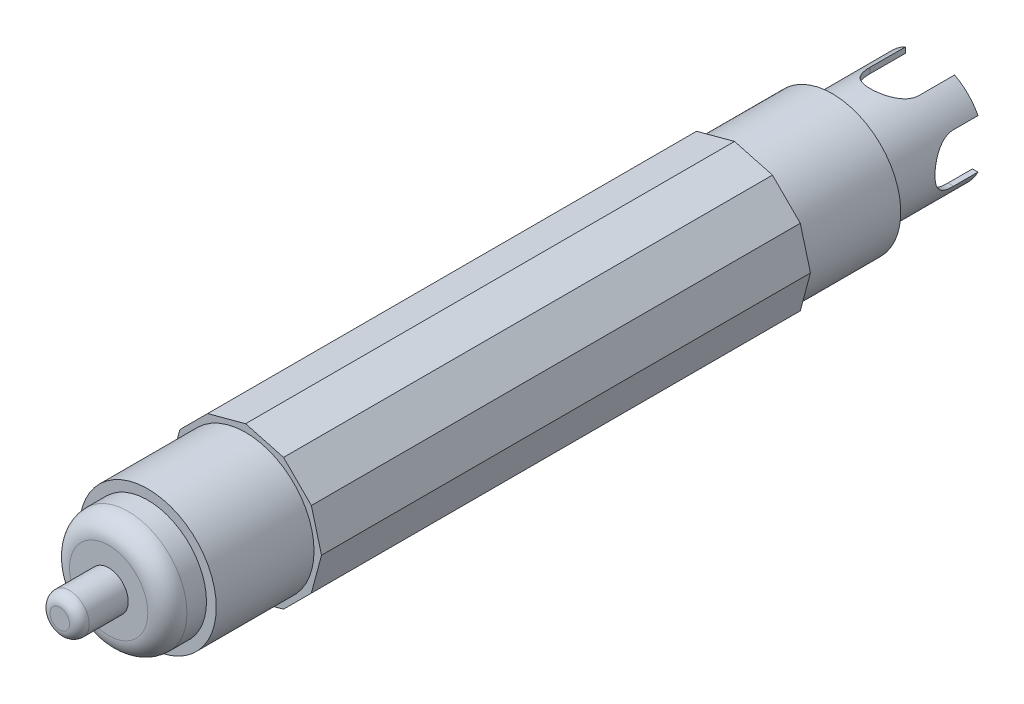
from build123d import *

# Parameters (mm, degrees)
BOSS_EXTRUDE1_DEPTH            = 100
SKETCH2_R                      = 14
BOSS_EXTRUDE2_DEPTH            = 20
SKETCH3_R                      = 12
BOSS_EXTRUDE3_DEPTH            = 8
FILLET1_R                      = 4
SKETCH4_R                      = 4
BOSS_EXTRUDE4_DEPTH            = 10
FILLET2_R                      = 2
SKETCH6_R                      = 14
BOSS_EXTRUDE6_DEPTH            = 20
SKETCH7_R                      = 11
SKETCH7_R_2                    = 10
BOSS_EXTRUDE7_DEPTH            = 20
CUT_EXTRUDE1_REACH             = 17.529
CUT_EXTRUDE1_DIRECTION_2_REACH = 17.529
CUT_EXTRUDE2_REACH             = 17.529
CUT_EXTRUDE2_DIRECTION_2_REACH = 17.529
SKETCH10_R                     = 10
BOSS_EXTRUDE8_DEPTH            = 8
SKETCH11_R                     = 3
BOSS_EXTRUDE9_DEPTH            = 6
FILLET3_R                      = 3


with BuildPart() as part:
    # Sketch1 → Boss-Extrude1 (new body)
    with BuildSketch(Plane.XY):
        Polygon((-15.529142706, 0), (-13.448632083, -7.764571353), (-7.764571353, -13.448632083), (0, -15.529142706), (7.764571353, -13.448632083), (13.448632083, -7.764571353), (15.529142706, 0), (13.448632083, 7.764571353), (7.764571353, 13.448632083), (0, 15.529142706), (-7.764571353, 13.448632083), (-13.448632083, 7.764571353), align=None)
    extrude(amount=-BOSS_EXTRUDE1_DEPTH)

    # Sketch2 → Boss-Extrude2 (add)
    with BuildSketch(Plane.XY):
        Circle(SKETCH2_R)
    extrude(amount=BOSS_EXTRUDE2_DEPTH)

    # Sketch3 → Boss-Extrude3 (add)
    with BuildSketch(Plane.XY.offset(20)):
        Circle(SKETCH3_R)
    extrude(amount=BOSS_EXTRUDE3_DEPTH)

    # Fillet1
    fillet1_edges = [part.edges().sort_by_distance(p)[0] for p in [
        (-12, 0, 28),
    ]]
    fillet(fillet1_edges, radius=FILLET1_R)

    # Sketch4 → Boss-Extrude4 (add)
    with BuildSketch(Plane.XY.offset(28)):
        Circle(SKETCH4_R)
    extrude(amount=BOSS_EXTRUDE4_DEPTH)

    # Fillet2
    fillet2_edges = [part.edges().sort_by_distance(p)[0] for p in [
        (-4, 0, 38),
    ]]
    fillet(fillet2_edges, radius=FILLET2_R)

    # Sketch6 → Boss-Extrude6 (add)
    with BuildSketch(Plane(origin=(0, 0, -100), x_dir=(-1, 0, 0), z_dir=(0, 0, -1))):
        Circle(SKETCH6_R)
    extrude(amount=BOSS_EXTRUDE6_DEPTH)

    # Sketch7 → Boss-Extrude7 (add)
    with BuildSketch(Plane(origin=(0, 0, -120), x_dir=(-1, 0, 0), z_dir=(0, 0, -1))):
        Circle(SKETCH7_R)
        Circle(SKETCH7_R_2, mode=Mode.SUBTRACT)
    extrude(amount=BOSS_EXTRUDE7_DEPTH)

    # Sketch8 → Cut-Extrude1 (cut, up to next)
    with BuildSketch(Plane(origin=(0, 0, 0), x_dir=(0, 0, -1), z_dir=(1, 0, 0)), mode=Mode.PRIVATE) as cut_extrude1_sk1:
        with BuildLine():
            Line((145, -5), (135, -5))
            ThreePointArc((135, -5), (130, 0), (135, 5))
            Line((135, 5), (145, 5))
            Line((145, 5), (145, -5))
        make_face()
    cut_extrude1_tool1 = extrude(cut_extrude1_sk1.sketch, amount=-CUT_EXTRUDE1_REACH, mode=Mode.PRIVATE) & part.part
    add(cut_extrude1_tool1.solids().sort_by_distance((0, 0, -137.991792))[0], mode=Mode.SUBTRACT)

    # Sketch8 → Cut-Extrude1 direction 2 (cut, up to next)
    with BuildSketch(Plane(origin=(0, 0, 0), x_dir=(0, 0, -1), z_dir=(1, 0, 0)), mode=Mode.PRIVATE) as cut_extrude1_direction_2_sk1:
        with BuildLine():
            Line((145, -5), (135, -5))
            ThreePointArc((135, -5), (130, 0), (135, 5))
            Line((135, 5), (145, 5))
            Line((145, 5), (145, -5))
        make_face()
    cut_extrude1_direction_2_tool1 = extrude(cut_extrude1_direction_2_sk1.sketch, amount=CUT_EXTRUDE1_DIRECTION_2_REACH, mode=Mode.PRIVATE) & part.part
    add(cut_extrude1_direction_2_tool1.solids().sort_by_distance((0, 0, -137.991792))[0], mode=Mode.SUBTRACT)

    # Sketch9 → Cut-Extrude2 (cut, up to next)
    with BuildSketch(Plane(origin=(0, 0, 0), x_dir=(1, 0, 0), z_dir=(0, 1, 0)), mode=Mode.PRIVATE) as cut_extrude2_sk1:
        with BuildLine():
            Line((-5, 132.755823636), (-5, 147.244176364))
            Line((-5, 147.244176364), (5, 147.244176364))
            Line((5, 147.244176364), (5, 132.755823636))
            ThreePointArc((5, 132.755823636), (0, 127.755823636), (-5, 132.755823636))
        make_face()
    cut_extrude2_tool1 = extrude(cut_extrude2_sk1.sketch, amount=-CUT_EXTRUDE2_REACH, mode=Mode.PRIVATE) & part.part
    add(cut_extrude2_tool1.solids().sort_by_distance((0, 0, -138.00269))[0], mode=Mode.SUBTRACT)

    # Sketch9 → Cut-Extrude2 direction 2 (cut, up to next)
    with BuildSketch(Plane(origin=(0, 0, 0), x_dir=(1, 0, 0), z_dir=(0, 1, 0)), mode=Mode.PRIVATE) as cut_extrude2_direction_2_sk1:
        with BuildLine():
            Line((-5, 132.755823636), (-5, 147.244176364))
            Line((-5, 147.244176364), (5, 147.244176364))
            Line((5, 147.244176364), (5, 132.755823636))
            ThreePointArc((5, 132.755823636), (0, 127.755823636), (-5, 132.755823636))
        make_face()
    cut_extrude2_direction_2_tool1 = extrude(cut_extrude2_direction_2_sk1.sketch, amount=CUT_EXTRUDE2_DIRECTION_2_REACH, mode=Mode.PRIVATE) & part.part
    add(cut_extrude2_direction_2_tool1.solids().sort_by_distance((0, 0, -138.00269))[0], mode=Mode.SUBTRACT)

    # Sketch10 → Boss-Extrude8 (add)
    with BuildSketch(Plane(origin=(0, 0, -120), x_dir=(-1, 0, 0), z_dir=(0, 0, -1))):
        Circle(SKETCH10_R)
    extrude(amount=BOSS_EXTRUDE8_DEPTH)

    # Sketch11 → Boss-Extrude9 (add)
    with BuildSketch(Plane(origin=(0, 0, -128), x_dir=(-1, 0, 0), z_dir=(0, 0, -1))):
        Circle(SKETCH11_R)
    extrude(amount=BOSS_EXTRUDE9_DEPTH)

    # Fillet3
    fillet3_edges = [part.edges().sort_by_distance(p)[0] for p in [
        (3, 0, -134),
    ]]
    fillet(fillet3_edges, radius=FILLET3_R)


solid = part.part
